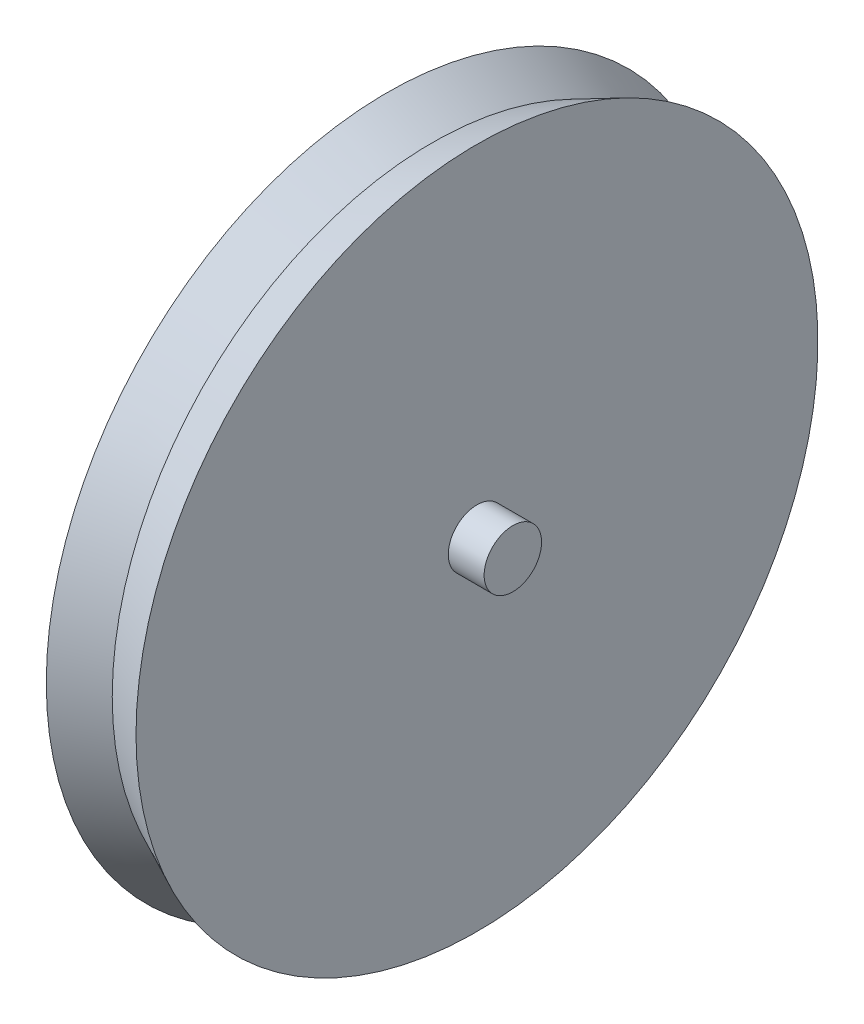
from build123d import *

# Parameters (mm, degrees)
SKETCH2_R                = 1.27
BOSS_EXTRUDE1_DEPTH      = 1.5875
BOSS_EXTRUDE1_DEPTH_BACK = 5.55625


with BuildPart() as part:
    # Sketch1 → Revolve1 (revolve)
    with BuildSketch(Plane(origin=(0, 0, 0), x_dir=(1, 0, 0), z_dir=(0, 1, 0))):
        Polygon((0, 0), (3.96875, 0), (3.96875, 15.08125), (1.984375, 14.148388583), (0, 15.08125), align=None)
    revolve(axis=Axis((0, 0, 0), (1, 0, 0)))

    # Sketch2 → Boss-Extrude1 (add, two sides)
    with BuildSketch(Plane(origin=(3.96875, 0, 0), x_dir=(0, 0, -1), z_dir=(1, 0, 0))) as boss_extrude1_sk:
        Circle(SKETCH2_R)
    extrude(amount=BOSS_EXTRUDE1_DEPTH)
    extrude(boss_extrude1_sk.sketch, amount=-BOSS_EXTRUDE1_DEPTH_BACK)


solid = part.part
